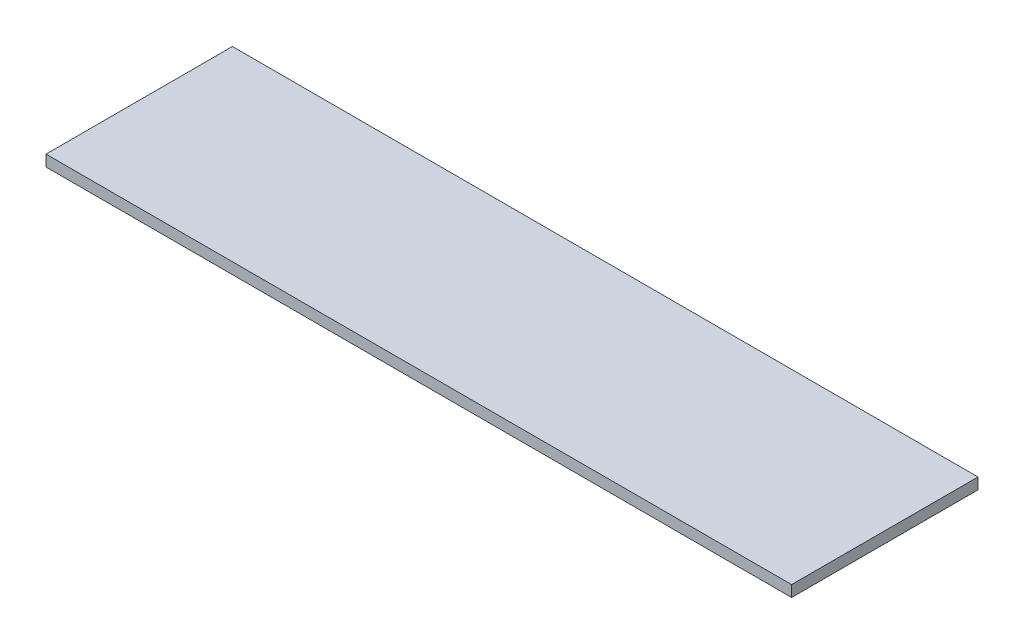
from build123d import *

# Parameters (mm, degrees)
SKETCH_1_W      = 100
SKETCH_1_H      = 25
EXTRUDE_1_DEPTH = 1.5


with BuildPart() as part:
    # Эскиз1 → Бобышка-Вытянуть1 (new body)
    with BuildSketch(Plane(origin=(0, 0, 0), x_dir=(1, 0, 0), z_dir=(0, 1, 0))):
        Rectangle(SKETCH_1_W, SKETCH_1_H)
    extrude(amount=EXTRUDE_1_DEPTH)


solid = part.part
